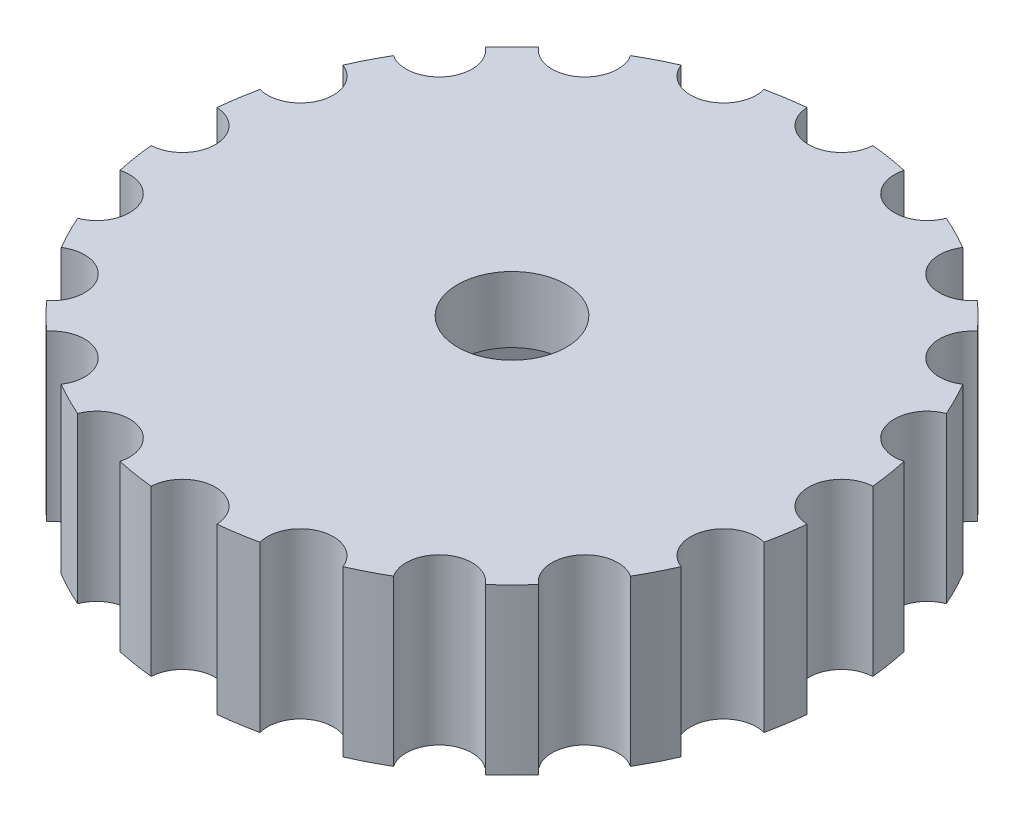
from build123d import *

# Parameters (mm, degrees)
ESBO_O1_W             = 8.35
ESBO_O1_H             = 5
CORTE_EXTRUS_O1_DEPTH = 3
ESBO_O4_R             = 1
CORTE_EXTRUS_O2_DEPTH = 10


with BuildPart() as part:
    # Esboço1 → Revolução1 (revolve)
    with BuildSketch(Plane.XY):
        with Locations((-5.825, 2.5)):
            Rectangle(ESBO_O1_W, ESBO_O1_H)
    revolve(axis=Axis((0, 0, 0), (0, 1, 0)))

    # Esboço3 → Corte-extrusão1 (cut)
    with BuildSketch(Plane.XZ):
        Polygon((3.175426481, 0), (1.58771324, 2.75), (-1.58771324, 2.75), (-3.175426481, 0), (-1.58771324, -2.75), (1.58771324, -2.75), align=None)
    extrude(amount=-CORTE_EXTRUS_O1_DEPTH, mode=Mode.SUBTRACT)

    # Esboço4 → Corte-extrusão2 (cut)
    with BuildSketch(Plane(origin=(0, 5, 0), x_dir=(1, 0, 0), z_dir=(0, 1, 0))):
        with Locations((0, 10)):
            Circle(ESBO_O4_R)
        with Locations((3.090169944, 9.510565163)):
            Circle(ESBO_O4_R)
        with Locations((5.877852523, 8.090169944)):
            Circle(ESBO_O4_R)
        with Locations((8.090169944, 5.877852523)):
            Circle(ESBO_O4_R)
        with Locations((9.510565163, 3.090169944)):
            Circle(ESBO_O4_R)
        with Locations((10, 0)):
            Circle(ESBO_O4_R)
        with Locations((9.510565163, -3.090169944)):
            Circle(ESBO_O4_R)
        with Locations((8.090169944, -5.877852523)):
            Circle(ESBO_O4_R)
        with Locations((5.877852523, -8.090169944)):
            Circle(ESBO_O4_R)
        with Locations((3.090169944, -9.510565163)):
            Circle(ESBO_O4_R)
        with Locations((0, -10)):
            Circle(ESBO_O4_R)
        with Locations((-3.090169944, -9.510565163)):
            Circle(ESBO_O4_R)
        with Locations((-5.877852523, -8.090169944)):
            Circle(ESBO_O4_R)
        with Locations((-8.090169944, -5.877852523)):
            Circle(ESBO_O4_R)
        with Locations((-9.510565163, -3.090169944)):
            Circle(ESBO_O4_R)
        with Locations((-10, 0)):
            Circle(ESBO_O4_R)
        with Locations((-9.510565163, 3.090169944)):
            Circle(ESBO_O4_R)
        with Locations((-8.090169944, 5.877852523)):
            Circle(ESBO_O4_R)
        with Locations((-5.877852523, 8.090169944)):
            Circle(ESBO_O4_R)
        with Locations((-3.090169944, 9.510565163)):
            Circle(ESBO_O4_R)
    extrude(amount=-CORTE_EXTRUS_O2_DEPTH, mode=Mode.SUBTRACT)


solid = part.part
